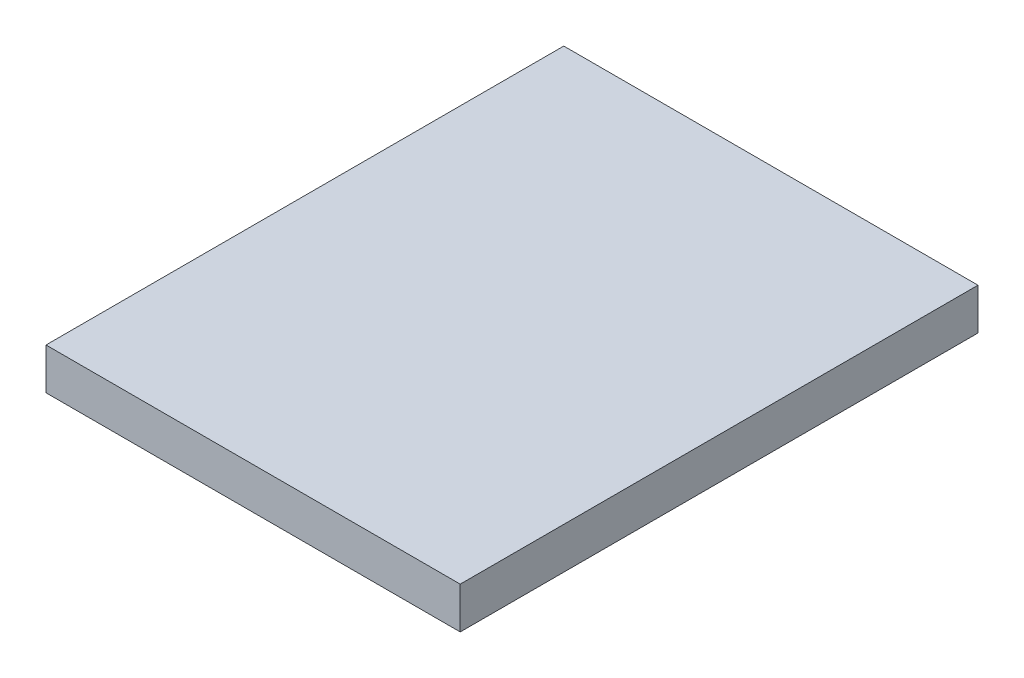
from build123d import *

# Parameters (mm, degrees)
SKETCH1_W           = 2000
SKETCH1_H           = 2500
BOSS_EXTRUDE1_DEPTH = 100


with BuildPart() as part:
    # Sketch1 → Boss-Extrude1 (new body, symmetric)
    with BuildSketch(Plane(origin=(0, 0, 0), x_dir=(1, 0, 0), z_dir=(0, 1, 0))):
        Rectangle(SKETCH1_W, SKETCH1_H)
    extrude(amount=BOSS_EXTRUDE1_DEPTH, both=True)


solid = part.part
